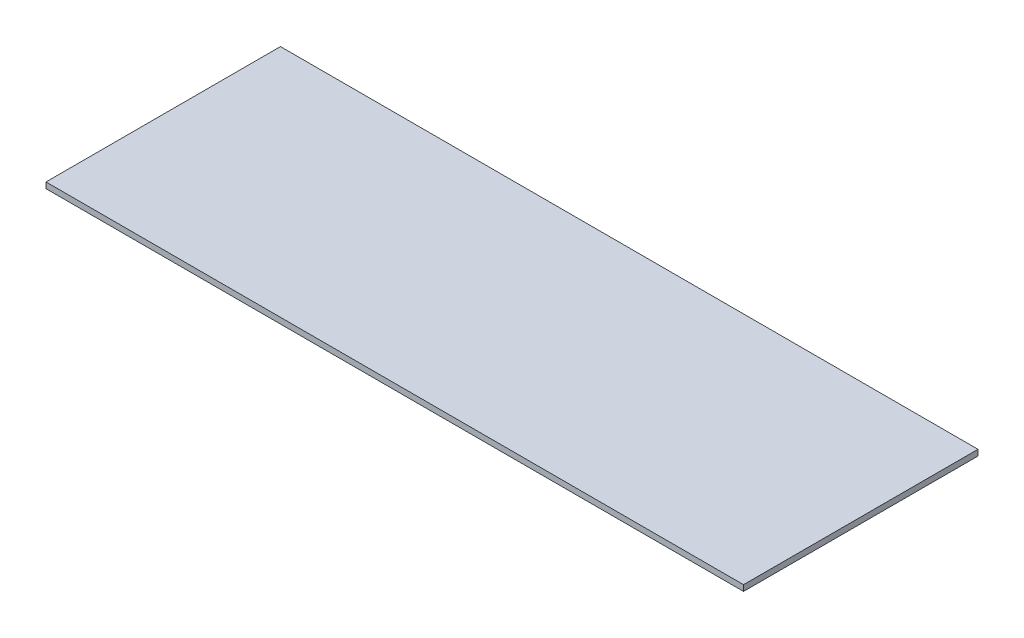
from build123d import *

# Parameters (mm, degrees)
SKETCH1_W           = 1511.3
SKETCH1_H           = 508
BOSS_EXTRUDE1_DEPTH = 12.7


with BuildPart() as part:
    # Sketch1 → Boss-Extrude1 (new body)
    with BuildSketch(Plane(origin=(0, 0, 0), x_dir=(1, 0, 0), z_dir=(0, 1, 0))):
        Rectangle(SKETCH1_W, SKETCH1_H)
    extrude(amount=BOSS_EXTRUDE1_DEPTH)


solid = part.part
